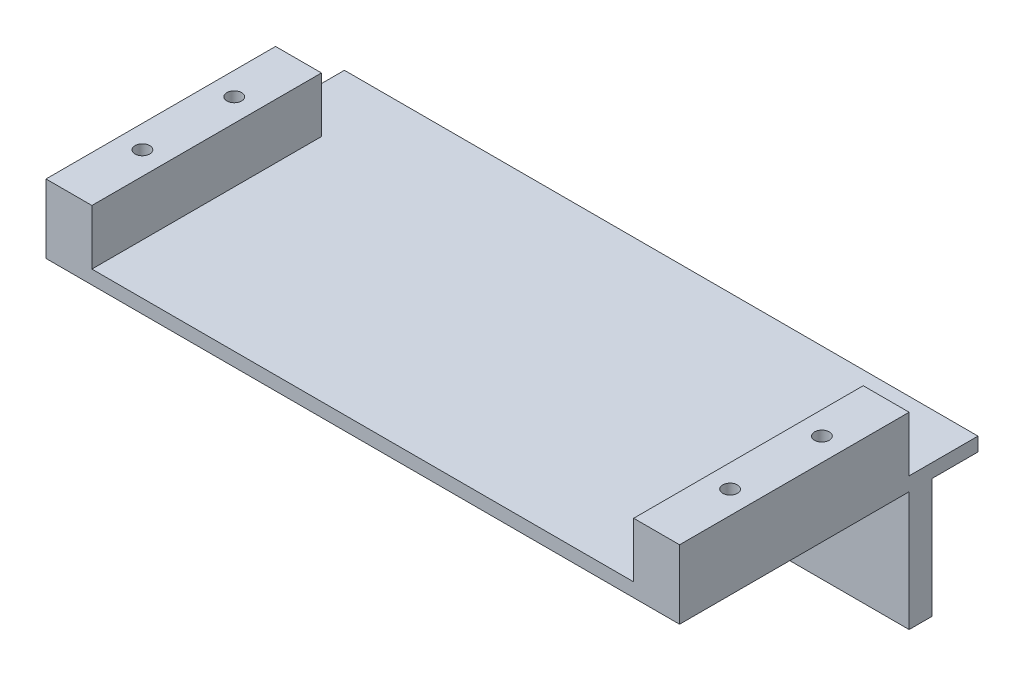
from build123d import *

# Parameters (mm, degrees)
SKETCH_1_W          = 138
SKETCH_1_H          = 26
SKETCH_1_R          = 2.1
EXTRUDE_1_DEPTH     = 5
SKETCH_2_W          = 138
SKETCH_2_H          = 65
EXTRUDE_2_DEPTH     = 3
SKETCH_3_R          = 1.6
CUT_EXTRUDE_1_DEPTH = 3
SKETCH_4_W          = 10
SKETCH_4_H          = 50
SKETCH_4_R          = 1.6
EXTRUDE_3_DEPTH     = 12


with BuildPart() as part:
    # 草图1 → 凸台-拉伸1 (new body)
    with BuildSketch(Plane.XY):
        with Locations((19.202020202, 1.570004208)):
            Rectangle(SKETCH_1_W, SKETCH_1_H)
        with Locations((-29.797979798, -1.429995792)):
            Circle(SKETCH_1_R, mode=Mode.SUBTRACT)
        with Locations((68.202020202, -1.429995792)):
            Circle(SKETCH_1_R, mode=Mode.SUBTRACT)
    extrude(amount=EXTRUDE_1_DEPTH)

    # 草图2 → 凸台-拉伸2 (add)
    with BuildSketch(Plane(origin=(0, 14.570004208, 0), x_dir=(1, 0, 0), z_dir=(0, 1, 0))):
        with Locations((19.202020202, -22.5)):
            Rectangle(SKETCH_2_W, SKETCH_2_H)
    extrude(amount=EXTRUDE_2_DEPTH)

    # 草图3 → 切除-拉伸1 (cut)
    with BuildSketch(Plane(origin=(0, 17.570004208, 0), x_dir=(1, 0, 0), z_dir=(0, 1, 0))):
        with Locations((-44.797979798, -19)):
            Circle(SKETCH_3_R)
        with Locations((-44.797979798, -39)):
            Circle(SKETCH_3_R)
        with Locations((83.202020202, -19)):
            Circle(SKETCH_3_R)
        with Locations((83.202020202, -39)):
            Circle(SKETCH_3_R)
    extrude(amount=-CUT_EXTRUDE_1_DEPTH, mode=Mode.SUBTRACT)

    # 草图4 → 凸台-拉伸3 (add)
    with BuildSketch(Plane(origin=(0, 17.570004208, 0), x_dir=(1, 0, 0), z_dir=(0, 1, 0))):
        with Locations((83.202020202, -30)):
            Rectangle(SKETCH_4_W, SKETCH_4_H)
        with Locations((83.202020202, -19)):
            Circle(SKETCH_4_R, mode=Mode.SUBTRACT)
        with Locations((83.202020202, -39)):
            Circle(SKETCH_4_R, mode=Mode.SUBTRACT)
        with Locations((-44.797979798, -30)):
            Rectangle(SKETCH_4_W, SKETCH_4_H)
        with Locations((-44.797979798, -39)):
            Circle(SKETCH_4_R, mode=Mode.SUBTRACT)
        with Locations((-44.797979798, -19)):
            Circle(SKETCH_4_R, mode=Mode.SUBTRACT)
    extrude(amount=EXTRUDE_3_DEPTH)


solid = part.part
